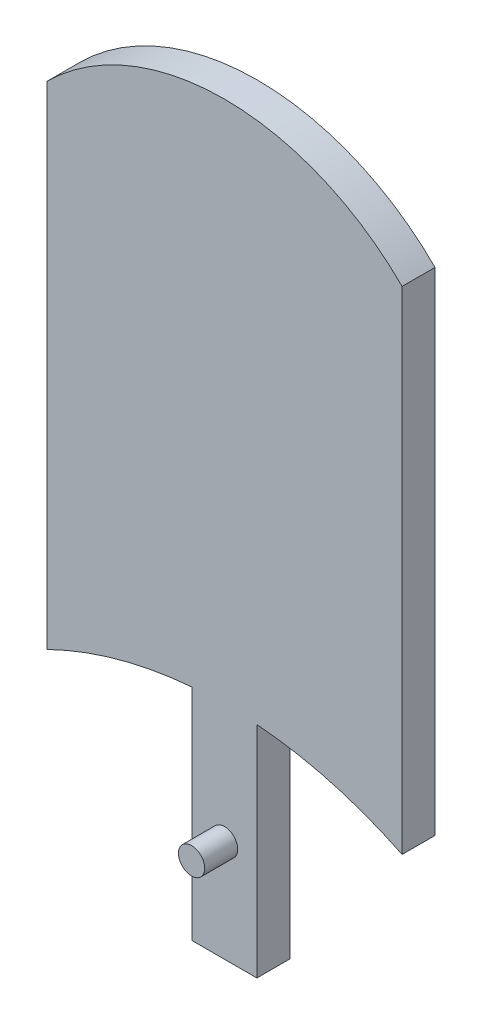
from build123d import *

# Parameters (mm, degrees)
BOSS_EXTRUDE1_DEPTH = 3.175
BOSS_EXTRUDE2_DEPTH = 3.175
SKETCH3_W           = 6.236959702
SKETCH3_H           = 41.352711554
BOSS_EXTRUDE3_DEPTH = 3.175
SKETCH4_R           = 1.27
BOSS_EXTRUDE4_DEPTH = 3.175
BOSS_EXTRUDE5_REACH = 20.766
SKETCH6_W           = 0.889
SKETCH6_H           = 43.066281197
CUT_EXTRUDE1_REACH  = 11.525


with BuildPart() as part:
    # Sketch1 → Boss-Extrude1 (new body)
    with BuildSketch(Plane.XY):
        with BuildLine():
            Line((-17.114253333, -23.707583903), (-17.114253333, 23.707583903))
            ThreePointArc((-17.114253333, 23.707583903), (0, 30.782200079), (17.114253333, 23.707583903))
            Line((17.114253333, 23.707583903), (17.114253333, -23.707583903))
            ThreePointArc((17.114253333, -23.707583903), (0, -19.732802645), (-17.114253333, -23.707583903))
        make_face()
    extrude(amount=BOSS_EXTRUDE1_DEPTH)

    # Sketch2 → Boss-Extrude2 (add)
    with BuildSketch(Plane(origin=(0, 0, 0), x_dir=(-1, 0, 0), z_dir=(0, 0, -1))):
        with BuildLine():
            Line((-1.65128862, -19.767928257), (-1.65128862, 22.268343179))
            Line((-1.65128862, 22.268343179), (-1.65128862, 23.29835294))
            Line((-1.65128862, 23.29835294), (-2.853426735, 23.29835294))
            Line((-2.853426735, 23.29835294), (-2.853426735, -19.837781624))
            ThreePointArc((-2.853426735, -19.837781624), (-2.25262846, -19.798194915), (-1.65128862, -19.767928257))
        make_face()
        with BuildLine():
            Line((1.65128862, 23.29835294), (1.65128862, 22.268343179))
            Line((1.65128862, 22.268343179), (1.65128862, -19.767928257))
            ThreePointArc((1.65128862, -19.767928257), (2.25262846, -19.798194915), (2.853426735, -19.837781624))
            Line((2.853426735, -19.837781624), (2.853426735, 23.29835294))
            Line((2.853426735, 23.29835294), (1.65128862, 23.29835294))
        make_face()
    extrude(amount=BOSS_EXTRUDE2_DEPTH)

    # Sketch3 → Boss-Extrude3 (add)
    with BuildSketch(Plane.XY.offset(3.175)):
        with Locations((0, -20.33746726)):
            Rectangle(SKETCH3_W, SKETCH3_H)
    extrude(amount=-BOSS_EXTRUDE3_DEPTH)

    # Sketch4 → Boss-Extrude4 (add)
    with BuildSketch(Plane.XY.offset(3.175)):
        with Locations((0, -31.201683403)):
            Circle(SKETCH4_R)
    extrude(amount=BOSS_EXTRUDE4_DEPTH)

    # Sketch6 → Boss-Extrude5 (add, up to next)
    with BuildSketch(Plane.ZY.offset(-1.65128862), mode=Mode.PRIVATE) as boss_extrude5_sk1:
        with Locations((-2.7305, 1.765212341)):
            Rectangle(SKETCH6_W, SKETCH6_H)
    boss_extrude5_tool1 = extrude(boss_extrude5_sk1.sketch, amount=BOSS_EXTRUDE5_REACH, mode=Mode.PRIVATE) - part.part
    add(boss_extrude5_tool1.solids().sort_by_distance((1.651289, 1.765212, -2.7305))[0])

    # Sketch8 → Cut-Extrude1 (cut, up to next)
    with BuildSketch(Plane(origin=(0, 0, -3.175), x_dir=(-1, 0, 0), z_dir=(0, 0, -1)), mode=Mode.PRIVATE) as cut_extrude1_sk1:
        Polygon((0, 23.29835294), (-1.016, 23.29835294), (-1.016, -19.767928257), (1.016, -19.767928257), (1.016, 23.29835294), align=None)
    cut_extrude1_tool1 = extrude(cut_extrude1_sk1.sketch, amount=-CUT_EXTRUDE1_REACH, mode=Mode.PRIVATE) & part.part
    add(cut_extrude1_tool1.solids().sort_by_distance((0, 1.765212, -3.175))[0], mode=Mode.SUBTRACT)


solid = part.part
